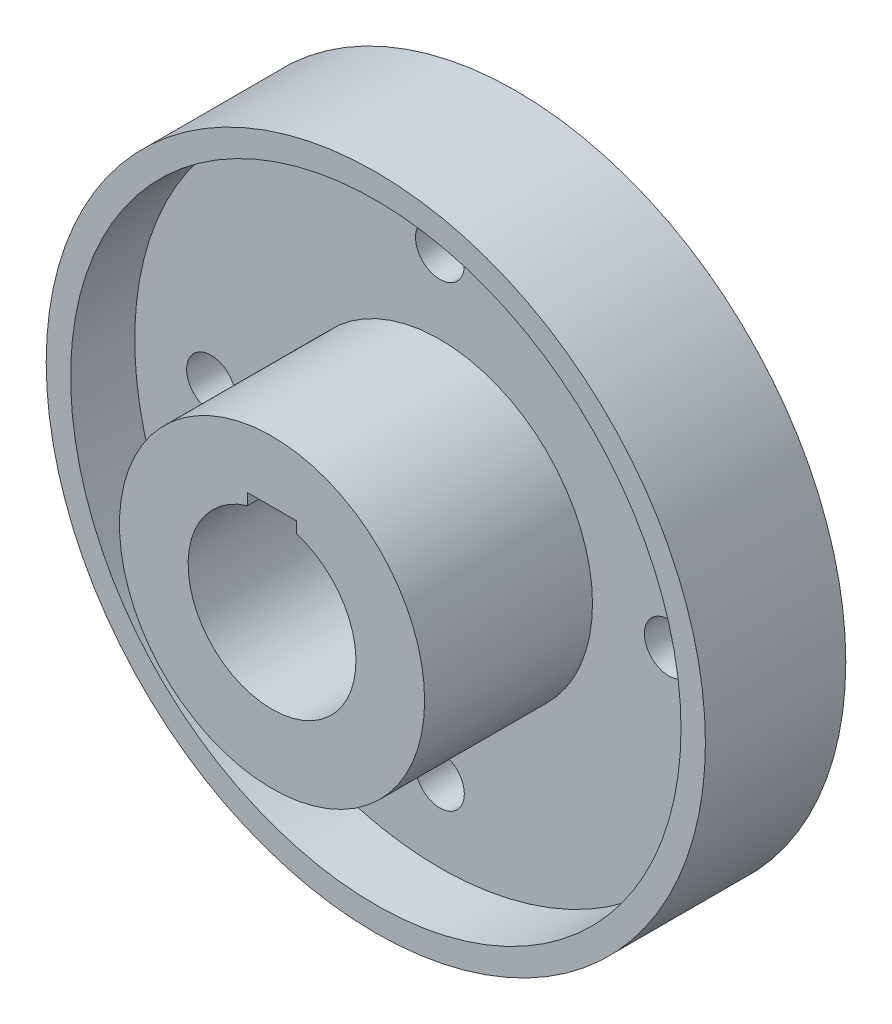
from build123d import *

# Parameters (mm, degrees)
SKETCH1_R           = 108
BOSS_EXTRUDE1_DEPTH = 25
SKETCH2_R           = 108
SKETCH2_R_2         = 100
BOSS_EXTRUDE2_DEPTH = 21
SKETCH3_R           = 50
SKETCH3_R_2         = 27.5
BOSS_EXTRUDE3_DEPTH = 55
SKETCH4_R           = 8
CUT_EXTRUDE1_DEPTH  = 26
SKETCH5_R           = 37.5
CUT_EXTRUDE2_DEPTH  = 6
SKETCH6_R           = 27.5
CUT_EXTRUDE4_DEPTH  = 26
SKETCH7_W           = 16
SKETCH7_H           = 30
CUT_EXTRUDE5_DEPTH  = 81


with BuildPart() as part:
    # Sketch1 → Boss-Extrude1 (new body)
    with BuildSketch(Plane.XY):
        Circle(SKETCH1_R)
    extrude(amount=BOSS_EXTRUDE1_DEPTH)

    # Sketch2 → Boss-Extrude2 (add)
    with BuildSketch(Plane.XY.offset(25)):
        Circle(SKETCH2_R)
        Circle(SKETCH2_R_2, mode=Mode.SUBTRACT)
    extrude(amount=BOSS_EXTRUDE2_DEPTH)

    # Sketch3 → Boss-Extrude3 (add)
    with BuildSketch(Plane.XY.offset(25)):
        Circle(SKETCH3_R)
        Circle(SKETCH3_R_2, mode=Mode.SUBTRACT)
    extrude(amount=BOSS_EXTRUDE3_DEPTH)

    # Sketch4 → Cut-Extrude1 (cut, through all)
    with BuildSketch(Plane.XY.offset(25)):
        with Locations((0, 75)):
            Circle(SKETCH4_R)
        with Locations((75, 0)):
            Circle(SKETCH4_R)
        with Locations((0, -75)):
            Circle(SKETCH4_R)
        with Locations((-75, 0)):
            Circle(SKETCH4_R)
    extrude(amount=-CUT_EXTRUDE1_DEPTH, mode=Mode.SUBTRACT)

    # Sketch5 → Cut-Extrude2 (cut)
    with BuildSketch(Plane(origin=(0, 0, 0), x_dir=(-1, 0, 0), z_dir=(0, 0, -1))):
        Circle(SKETCH5_R)
    extrude(amount=-CUT_EXTRUDE2_DEPTH, mode=Mode.SUBTRACT)

    # Sketch6 → Cut-Extrude4 (cut, through all)
    with BuildSketch(Plane.XY.offset(25)):
        Circle(SKETCH6_R)
    extrude(amount=-CUT_EXTRUDE4_DEPTH, mode=Mode.SUBTRACT)

    # Sketch7 → Cut-Extrude5 (cut, through all)
    with BuildSketch(Plane.XY.offset(80)):
        with Locations((0, 15)):
            Rectangle(SKETCH7_W, SKETCH7_H)
    extrude(amount=-CUT_EXTRUDE5_DEPTH, mode=Mode.SUBTRACT)


solid = part.part
